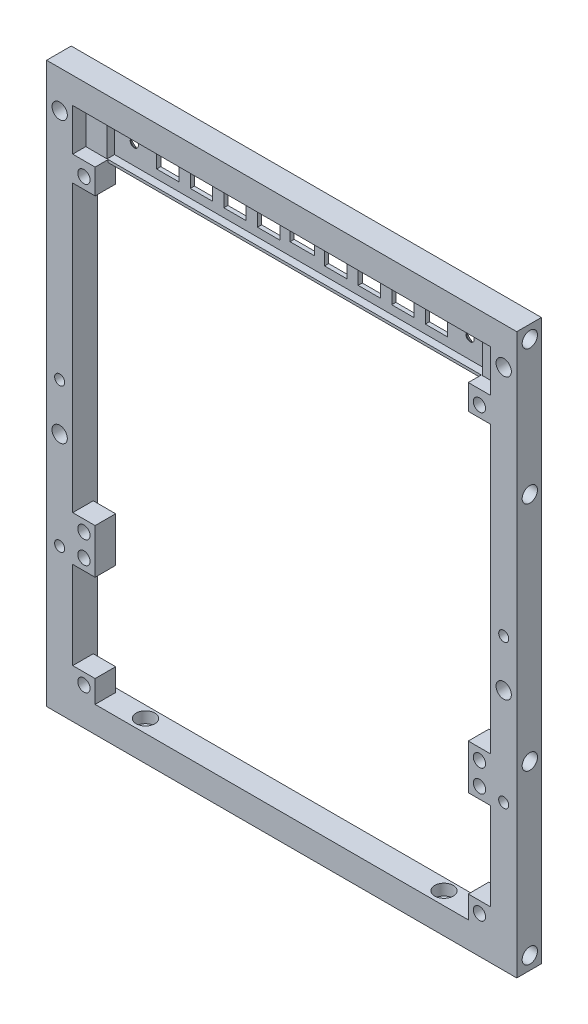
from build123d import *

# Parameters (mm, degrees)
SKETCH1_W                = 126
SKETCH1_H                = 150
SKETCH1_W_2              = 112
SKETCH1_H_2              = 136
BOSS_EXTRUDE1_DEPTH      = 7
SKETCH2_R                = 2.05
CUT_EXTRUDE1_DEPTH       = 6
SKETCH3_R                = 1.35
CUT_EXTRUDE2_DEPTH       = 157.419308271
SKETCH4_R                = 2.5
CUT_EXTRUDE3_DEPTH       = 3
SKETCH5_R                = 1.35
CUT_EXTRUDE4_DEPTH       = 99.198777996
SKETCH6_R                = 2.5
CUT_EXTRUDE5_DEPTH       = 3
SKETCH7_R                = 2.05
CUT_EXTRUDE6_DEPTH       = 99.198777996
CUT_EXTRUDE7_DEPTH       = 0.2
SKETCH9_W                = 2.7
SKETCH9_H                = 2.7
CUT_EXTRUDE8_DEPTH       = 0.2
SKETCH10_W               = 6
SKETCH10_H               = 6
BOSS_EXTRUDE2_DEPTH      = 5.5
SKETCH11_R               = 1.65
CUT_EXTRUDE9_DEPTH       = 99.103261923
SKETCH12_W               = 112
SKETCH12_H               = 12
BOSS_EXTRUDE3_DEPTH      = 1.5
SKETCH13_W               = 112
SKETCH13_H               = 12
SKETCH13_W_2             = 100.6
SKETCH13_H_2             = 10.6
BOSS_EXTRUDE4_DEPTH      = 2
SKETCH14_W               = 6
SKETCH14_H               = 6
SKETCH14_W_2             = 6.5
SKETCH14_H_2             = 4
CUT_EXTRUDE10_DEPTH      = 99.103261923
SKETCH15_R               = 1
BOSS_EXTRUDE5_DEPTH      = 2
CHAMFER1_SIZE            = 0.4
CHAMFER2_SIZE            = 0.4
CHAMFER3_SIZE            = 0.4
SKETCH16_W               = 6
SKETCH16_H               = 6
BOSS_EXTRUDE7_DEPTH      = 5.5
SKETCH17_R               = 1.65
CUT_EXTRUDE11_DEPTH      = 99.103261923
SKETCH18_R               = 1.1
CUT_EXTRUDE12_DEPTH      = 99.103261923
CUT_EXTRUDE12_DEPTH_BACK = 99.103261923
CHAMFER4_SIZE            = 1.3


with BuildPart() as part:
    # Sketch1 → Boss-Extrude1 (new body)
    with BuildSketch(Plane.XY):
        Rectangle(SKETCH1_W, SKETCH1_H)
        Rectangle(SKETCH1_W_2, SKETCH1_H_2, mode=Mode.SUBTRACT)
    extrude(amount=BOSS_EXTRUDE1_DEPTH)

    # Sketch2 → Cut-Extrude1 (cut)
    with BuildSketch(Plane.ZY.offset(63)):
        with Locations((3.5, -71.5)):
            Circle(SKETCH2_R)
        with Locations((3.5, 71.5)):
            Circle(SKETCH2_R)
        with Locations((3.5, 35.5)):
            Circle(SKETCH2_R)
        with Locations((3.5, -26.5)):
            Circle(SKETCH2_R)
    cut_extrude1 = extrude(amount=-CUT_EXTRUDE1_DEPTH, mode=Mode.SUBTRACT)

    # Mirror1: Cut-Extrude1 across plane
    add(cut_extrude1.mirror(Plane(origin=(0, 0, 0), x_dir=(0, 0, 1), z_dir=(1, 0, 0))), mode=Mode.SUBTRACT)

    # Sketch3 → Cut-Extrude2 (cut, through all)
    with BuildSketch(Plane(origin=(0, -68, 0), x_dir=(1, 0, 0), z_dir=(0, 1, 0))):
        with Locations(Location((40, -3.5, 0), (0, 0, 270))):
            Circle(SKETCH3_R)
        with Locations(Location((-40, -3.5, 0), (0, 0, 270))):
            Circle(SKETCH3_R)
    extrude(amount=-CUT_EXTRUDE2_DEPTH, mode=Mode.SUBTRACT)

    # Sketch4 → Cut-Extrude3 (cut)
    with BuildSketch(Plane(origin=(0, -68, 0), x_dir=(1, 0, 0), z_dir=(0, 1, 0))):
        with Locations(Location((40, -3.5, 0), (0, 0, 270))):
            Circle(SKETCH4_R)
        with Locations(Location((-40, -3.5, 0), (0, 0, 270))):
            Circle(SKETCH4_R)
    extrude(amount=-CUT_EXTRUDE3_DEPTH, mode=Mode.SUBTRACT)

    # Sketch5 → Cut-Extrude4 (cut, through all)
    with BuildSketch(Plane(origin=(0, 0, 0), x_dir=(-1, 0, 0), z_dir=(0, 0, -1))):
        with Locations((-59.5, 2.6)):
            Circle(SKETCH5_R)
        with Locations(Location((59.5, 2.6, 0), (0, 0, 180))):
            Circle(SKETCH5_R)
        with Locations((-59.5, -36)):
            Circle(SKETCH5_R)
        with Locations(Location((59.5, -36, 0), (0, 0, 180))):
            Circle(SKETCH5_R)
    extrude(amount=-CUT_EXTRUDE4_DEPTH, mode=Mode.SUBTRACT)

    # Sketch6 → Cut-Extrude5 (cut)
    with BuildSketch(Plane(origin=(0, 0, 0), x_dir=(-1, 0, 0), z_dir=(0, 0, -1))):
        with Locations((-59.5, 2.6)):
            Circle(SKETCH6_R)
        with Locations((59.5, 2.6)):
            Circle(SKETCH6_R)
        with Locations((-59.5, -36)):
            Circle(SKETCH6_R)
        with Locations((59.5, -36)):
            Circle(SKETCH6_R)
    extrude(amount=-CUT_EXTRUDE5_DEPTH, mode=Mode.SUBTRACT)

    # Sketch7 → Cut-Extrude6 (cut, through all)
    with BuildSketch(Plane(origin=(0, 0, 0), x_dir=(-1, 0, 0), z_dir=(0, 0, -1))):
        with Locations((-59.5, 65)):
            Circle(SKETCH7_R)
        with Locations((-59.5, -10)):
            Circle(SKETCH7_R)
    cut_extrude6 = extrude(amount=-CUT_EXTRUDE6_DEPTH, mode=Mode.SUBTRACT)

    # Mirror2: Cut-Extrude6 across plane
    add(cut_extrude6.mirror(Plane(origin=(0, 0, 0), x_dir=(0, 0, 1), z_dir=(1, 0, 0))), mode=Mode.SUBTRACT)

    # Sketch8 → Cut-Extrude7 (cut)
    with BuildSketch(Plane(origin=(0, 0, 3), x_dir=(-1, 0, 0), z_dir=(0, 0, -1))):
        with BuildLine():
            Line((-60.85, 0.495837459), (-60.85, 4.704162541))
            ThreePointArc((-60.85, 4.704162541), (-59.5, 5.1), (-58.15, 4.704162541))
            Line((-58.15, 4.704162541), (-58.15, 0.495837459))
            ThreePointArc((-58.15, 0.495837459), (-59.5, 0.1), (-60.85, 0.495837459))
        make_face()
        with BuildLine():
            Line((-60.85, -38.104162541), (-60.85, -33.895837459))
            ThreePointArc((-60.85, -33.895837459), (-59.5, -33.5), (-58.15, -33.895837459))
            Line((-58.15, -33.895837459), (-58.15, -38.104162541))
            ThreePointArc((-58.15, -38.104162541), (-59.5, -38.5), (-60.85, -38.104162541))
        make_face()
    cut_extrude7 = extrude(amount=-CUT_EXTRUDE7_DEPTH, mode=Mode.SUBTRACT)

    # Sketch9 → Cut-Extrude8 (cut)
    with BuildSketch(Plane(origin=(0, 0, 3.2), x_dir=(-1, 0, 0), z_dir=(0, 0, -1))):
        with Locations((-59.5, 2.6)):
            Rectangle(SKETCH9_W, SKETCH9_H)
        with Locations((-59.5, -36)):
            Rectangle(SKETCH9_W, SKETCH9_H)
    cut_extrude8 = extrude(amount=-CUT_EXTRUDE8_DEPTH, mode=Mode.SUBTRACT)

    # Mirror3: Cut-Extrude7, Cut-Extrude8 across plane
    add(cut_extrude7.mirror(Plane(origin=(0, 0, 0), x_dir=(0, 0, 1), z_dir=(1, 0, 0))), mode=Mode.SUBTRACT)
    add(cut_extrude8.mirror(Plane(origin=(0, 0, 0), x_dir=(0, 0, 1), z_dir=(1, 0, 0))), mode=Mode.SUBTRACT)

    # Sketch10 → Boss-Extrude2 (add)
    with BuildSketch(Plane.XY.offset(7)):
        with Locations((53, -65)):
            Rectangle(SKETCH10_W, SKETCH10_H)
        with Locations((53, -35.5)):
            Rectangle(SKETCH10_W, SKETCH10_H)
    boss_extrude2 = extrude(amount=-BOSS_EXTRUDE2_DEPTH)

    # Sketch11 → Cut-Extrude9 (cut, through all)
    with BuildSketch(Plane(origin=(0, 0, 1.5), x_dir=(-1, 0, 0), z_dir=(0, 0, -1))):
        with Locations((-53, -35.5)):
            Circle(SKETCH11_R)
        with Locations((-53, -65)):
            Circle(SKETCH11_R)
    cut_extrude9 = extrude(amount=-CUT_EXTRUDE9_DEPTH, mode=Mode.SUBTRACT)

    # Mirror4: Boss-Extrude2, Cut-Extrude9 across plane
    add(boss_extrude2.mirror(Plane(origin=(0, 0, 0), x_dir=(0, 0, 1), z_dir=(1, 0, 0))))
    add(cut_extrude9.mirror(Plane(origin=(0, 0, 0), x_dir=(0, 0, 1), z_dir=(1, 0, 0))), mode=Mode.SUBTRACT)

    # Sketch12 → Boss-Extrude3 (add)
    with BuildSketch(Plane(origin=(0, 0, 0), x_dir=(-1, 0, 0), z_dir=(0, 0, -1))):
        with Locations((0, 62)):
            Rectangle(SKETCH12_W, SKETCH12_H)
    extrude(amount=-BOSS_EXTRUDE3_DEPTH)

    # Sketch13 → Boss-Extrude4 (add)
    with BuildSketch(Plane.XY.offset(1.5)):
        with Locations((0, 62)):
            Rectangle(SKETCH13_W, SKETCH13_H)
        with Locations((0, 62)):
            Rectangle(SKETCH13_W_2, SKETCH13_H_2, mode=Mode.SUBTRACT)
    extrude(amount=BOSS_EXTRUDE4_DEPTH)

    # Sketch14 → Cut-Extrude10 (cut, through all)
    with BuildSketch(Plane.XY.offset(1.5)):
        with Locations((-36, 62)):
            Rectangle(SKETCH14_W, SKETCH14_H)
        with Locations((0, 62)):
            Rectangle(SKETCH14_W_2, SKETCH14_H_2)
        with Locations((9, 62)):
            Rectangle(SKETCH14_W, SKETCH14_H)
        with Locations((18, 62)):
            Rectangle(SKETCH14_W, SKETCH14_H)
        with Locations((27, 62)):
            Rectangle(SKETCH14_W, SKETCH14_H)
        with Locations((36, 62)):
            Rectangle(SKETCH14_W, SKETCH14_H)
        with Locations((-27, 62)):
            Rectangle(SKETCH14_W, SKETCH14_H)
        with Locations((-18, 62)):
            Rectangle(SKETCH14_W, SKETCH14_H)
        with Locations((-9, 62)):
            Rectangle(SKETCH14_W, SKETCH14_H)
    extrude(amount=-CUT_EXTRUDE10_DEPTH, mode=Mode.SUBTRACT)

    # Sketch15 → Boss-Extrude5 (add)
    with BuildSketch(Plane.XY.offset(1.5)):
        with Locations(Location((-45, 62, 0), (0, 0, 180))):
            Circle(SKETCH15_R)
        with Locations(Location((45, 62, 0), (0, 0, 180))):
            Circle(SKETCH15_R)
    extrude(amount=BOSS_EXTRUDE5_DEPTH)

    # Chamfer1
    chamfer1_edges = [part.edges().sort_by_distance(p)[0] for p in [
        (56, -6, 0),
        (0, -68, 0),
        (-56, -6, 0),
        (0, 56, 0),
    ]]
    chamfer(chamfer1_edges, length=CHAMFER1_SIZE)

    # Chamfer2
    chamfer2_edges = [part.edges().sort_by_distance(p)[0] for p in [
        (0, -75, 0),
        (-63, 0, 0),
        (0, 75, 0),
        (63, 0, 0),
    ]]
    chamfer(chamfer2_edges, length=CHAMFER2_SIZE)

    # Chamfer3
    chamfer3_edges = [part.edges().sort_by_distance(p)[0] for p in [
        (-6, 62, 0),
        (-9, 59, 0),
        (-12, 62, 0),
        (-9, 65, 0),
        (-15, 62, 0),
        (-18, 59, 0),
        (-21, 62, 0),
        (-18, 65, 0),
        (-24, 62, 0),
        (-27, 59, 0),
        (-30, 62, 0),
        (-27, 65, 0),
        (-33, 62, 0),
        (-36, 59, 0),
        (-39, 62, 0),
        (-36, 65, 0),
        (39, 62, 0),
        (36, 59, 0),
        (33, 62, 0),
        (36, 65, 0),
        (30, 62, 0),
        (27, 59, 0),
        (24, 62, 0),
        (27, 65, 0),
        (21, 62, 0),
        (18, 59, 0),
        (15, 62, 0),
        (18, 65, 0),
        (12, 62, 0),
        (9, 59, 0),
        (6, 62, 0),
        (9, 65, 0),
        (3.25, 62, 0),
        (0, 60, 0),
        (-3.25, 62, 0),
        (0, 64, 0),
    ]]
    chamfer(chamfer3_edges, length=CHAMFER3_SIZE)

    # Sketch16 → Boss-Extrude7 (add)
    with BuildSketch(Plane.XY.offset(7)):
        Polygon((-50, 56), (-50, 56.7), (-56, 56.7), (-56, 56), (-56, 50), (-50, 50), align=None)
        with Locations((-53, -29.5)):
            Rectangle(SKETCH16_W, SKETCH16_H)
        with Locations((53, -29.5)):
            Rectangle(SKETCH16_W, SKETCH16_H)
        Polygon((56, 56), (56, 50), (50, 50), (50, 56), (50, 56.7), (56, 56.7), align=None)
    extrude(amount=-BOSS_EXTRUDE7_DEPTH)

    # Sketch17 → Cut-Extrude11 (cut, through all)
    with BuildSketch(Plane(origin=(0, 0, 1.5), x_dir=(-1, 0, 0), z_dir=(0, 0, -1))):
        with Locations((-53, -29.5)):
            Circle(SKETCH17_R)
        with Locations((53, -29.5)):
            Circle(SKETCH17_R)
        with Locations((53, 53)):
            Circle(SKETCH17_R)
        with Locations((-53, 53)):
            Circle(SKETCH17_R)
    extrude(amount=-CUT_EXTRUDE11_DEPTH, mode=Mode.SUBTRACT)

    # Sketch18 → Cut-Extrude12 (cut, two sides)
    with BuildSketch(Plane.XY.offset(1.5)) as cut_extrude12_sk:
        with Locations((-45, 62)):
            Circle(SKETCH18_R)
        with Locations((45, 62)):
            Circle(SKETCH18_R)
    extrude(amount=CUT_EXTRUDE12_DEPTH, mode=Mode.SUBTRACT)
    extrude(cut_extrude12_sk.sketch, amount=-CUT_EXTRUDE12_DEPTH_BACK, mode=Mode.SUBTRACT)

    # Chamfer4
    chamfer4_edges = [part.edges().sort_by_distance(p)[0] for p in [
        (-46.1, 62, 0),
        (43.9, 62, 0),
    ]]
    chamfer(chamfer4_edges, length=CHAMFER4_SIZE)


solid = part.part
